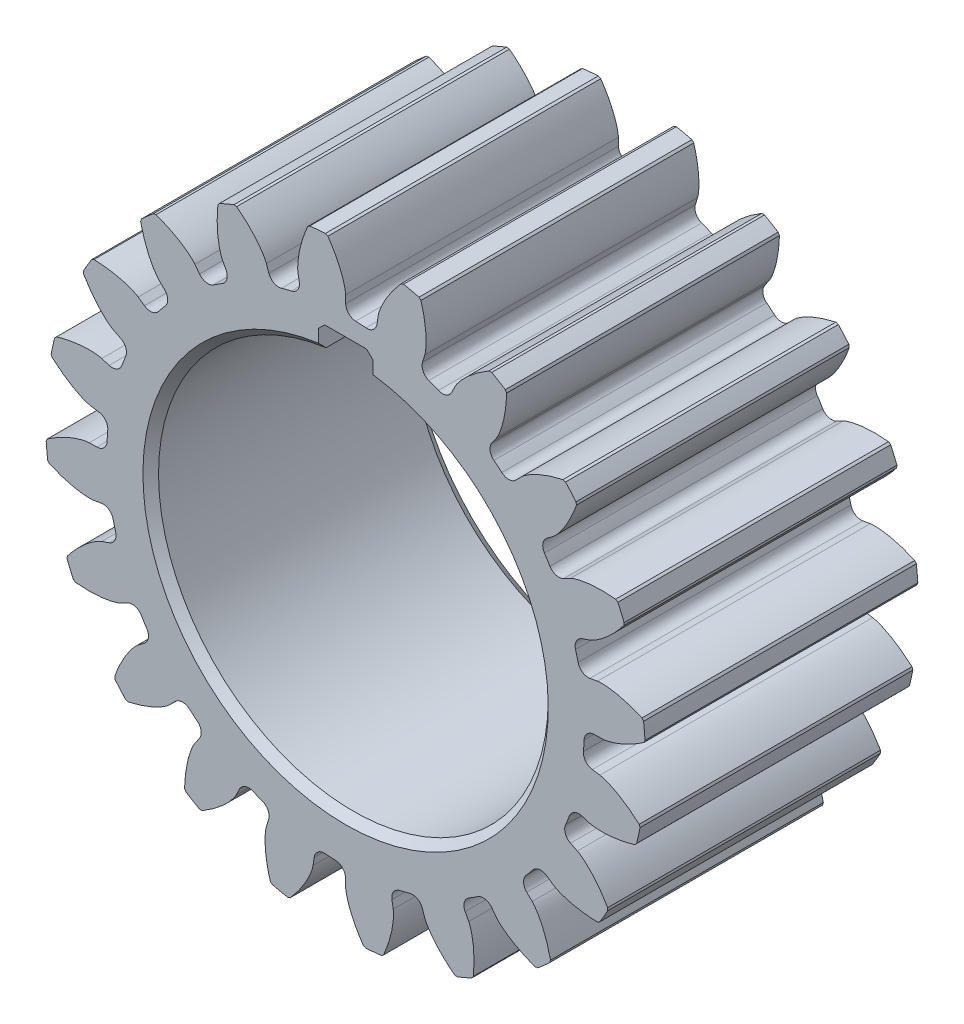
from build123d import *

# Parameters (mm, degrees)
SKETCH1_R                    = 30.625
BOSS_EXTRUDE1_DEPTH          = 35
BOSS_EXTRUDE2_DEPTH          = 35
CHAMFER1_SIZE                = 0.2
CIRPATTERN1_COUNT            = 20
CHAMFER1_OF_CIRPATTERN1_SIZE = 0.2
CUT_EXTRUDE1_DEPTH           = 35
CHAMFER2_SIZE                = 1
CHAMFER3_SIZE                = 1.6
CHAMFER4_SIZE                = 0.8


with BuildPart() as part:
    # Sketch1 → Boss-Extrude1 (new body)
    with BuildSketch(Plane.XY):
        Circle(SKETCH1_R)
    extrude(amount=BOSS_EXTRUDE1_DEPTH)

    # Sketch2 → Boss-Extrude2 (add)
    with BuildSketch(Plane.XY):
        with BuildLine():
            Line((32.8892, 0), (31.907011523, -0.014546372))
            ThreePointArc((31.907011523, -0.014546372), (30.99916734, -0.391210941), (30.597884469, -1.2884452))
            ThreePointArc((30.597884469, -1.2884452), (30.491389178, 2.857588319), (29.825681123, 6.951213604))
            ThreePointArc((29.825681123, 6.951213604), (30.386685965, 6.144162908), (31.34870745, 5.942738183))
            Line((31.34870745, 5.942738183), (32.316495712, 6.110939495))
            add(Edge.make_bspline(
                [(32.316495712, 6.110939495), (32.328235428, 6.112979855), (32.361254802, 6.118163923), (32.424031495, 6.125835398), (32.526887954, 6.135317243), (32.658500464, 6.14292963), (32.829135085, 6.14762534), (33.030708255, 6.146535461), (33.252680569, 6.138393743), (33.49451511, 6.122040937), (33.735966007, 6.099098571), (33.976890843, 6.07004769), (34.216880007, 6.035549617), (34.507456504, 5.987202414), (34.855635032, 5.920114134), (35.261931074, 5.828456236), (35.721707355, 5.70889906), (36.188774792, 5.570447222), (36.646979723, 5.420587717), (37.107925684, 5.253614676), (37.546364428, 5.08340366), (37.884256195, 4.940092177), (38.096323474, 4.847380273), (38.199445631, 4.801286645)],
                knots=[0, 0, 0, 0, 0, 0.005376749, 0.015083688, 0.02853182, 0.04661014, 0.064854849, 0.092110525, 0.119476176, 0.146842496, 0.174208854, 0.201574956, 0.228941013, 0.256307345, 0.307035032, 0.361767352, 0.416499661, 0.471231937, 0.525964282, 0.580696616, 0.635428982, 0.687157846, 0.687157846, 0.687157846, 0.687157846, 0.687157846], degree=4))
            ThreePointArc((38.199445631, 4.801286645), (38.332032109, 3.592396744), (38.426370758, 2.379922337))
            add(Edge.make_bspline(
                [(32.8892, 0), (32.901114397, 0.000176454), (32.93452202, 0.001217783), (32.997630963, 0.005344042), (33.100458131, 0.015138431), (33.231193264, 0.032112709), (33.399729081, 0.059203332), (33.597589726, 0.097727301), (33.814184042, 0.146970554), (34.048769069, 0.207972391), (34.281752769, 0.275377761), (34.513084581, 0.348687534), (34.742484906, 0.427175794), (35.019018458, 0.528671348), (35.348668844, 0.659284316), (35.730859607, 0.824837525), (36.160415556, 1.027741031), (36.593625, 1.250564909), (37.016006672, 1.482951122), (37.437901885, 1.732662166), (37.837080173, 1.981372874), (38.142460361, 2.18497044), (38.333608654, 2.315470851), (38.426370758, 2.379922337)],
                knots=[0, 0, 0, 0, 0, 0.005376749, 0.015083688, 0.02853182, 0.04661014, 0.064854849, 0.092110525, 0.119476176, 0.146842496, 0.174208854, 0.201574956, 0.228941013, 0.256307345, 0.307035032, 0.361767352, 0.416499661, 0.471231937, 0.525964282, 0.580696616, 0.635428982, 0.687157846, 0.687157846, 0.687157846, 0.687157846, 0.687157846], degree=4))
        make_face()
    boss_extrude2 = extrude(amount=BOSS_EXTRUDE2_DEPTH)

    # Chamfer1
    chamfer1_edges = [part.edges().sort_by_distance(p)[0] for p in [
        (38.199445631, 4.801286645, 17.5),
        (38.426370758, 2.379922337, 17.5),
    ]]
    chamfer(chamfer1_edges, length=CHAMFER1_SIZE)

    # CirPattern1: Boss-Extrude2 ×20 about axis
    cirpattern1_axis = Axis((0, 0, 35), (0, 0, -1))
    for i in range(1, CIRPATTERN1_COUNT):
        add(boss_extrude2.rotate(cirpattern1_axis, i * 360 / CIRPATTERN1_COUNT))

    # Chamfer1 of CirPattern1
    chamfer1_of_cirpattern1_edges = [part.edges().sort_by_distance(p)[0] for p in [
        (37.813510855, -7.237982925, 17.5),
        (37.281086755, -9.610960949, 17.5),
        (33.726126174, -18.568748297, 17.5),
        (32.486470227, -20.661056415, 17.5),
        (26.337393279, -28.081875209, 17.5),
        (24.511851647, -29.688703724, 17.5),
        (16.370572826, -34.846152518, 17.5),
        (14.137842244, -35.81021386, 17.5),
        (4.801286645, -38.199445631, 17.5),
        (2.379922337, -38.426370758, 17.5),
        (-7.237982925, -37.813510855, 17.5),
        (-9.610960949, -37.281086755, 17.5),
        (-18.568748297, -33.726126174, 17.5),
        (-20.661056415, -32.486470227, 17.5),
        (-28.081875209, -26.337393279, 17.5),
        (-29.688703724, -24.511851647, 17.5),
        (-34.846152518, -16.370572826, 17.5),
        (-35.81021386, -14.137842244, 17.5),
        (-38.199445631, -4.801286645, 17.5),
        (-38.426370758, -2.379922337, 17.5),
        (-37.813510855, 7.237982925, 17.5),
        (-37.281086755, 9.610960949, 17.5),
        (-33.726126174, 18.568748297, 17.5),
        (-32.486470227, 20.661056415, 17.5),
        (-26.337393279, 28.081875209, 17.5),
        (-24.511851647, 29.688703724, 17.5),
        (-16.370572826, 34.846152518, 17.5),
        (-14.137842244, 35.81021386, 17.5),
        (-4.801286645, 38.199445631, 17.5),
        (-2.379922337, 38.426370758, 17.5),
        (7.237982925, 37.813510855, 17.5),
        (9.610960949, 37.281086755, 17.5),
        (18.568748297, 33.726126174, 17.5),
        (20.661056415, 32.486470227, 17.5),
        (28.081875209, 26.337393279, 17.5),
        (29.688703724, 24.511851647, 17.5),
        (34.846152518, 16.370572826, 17.5),
        (35.81021386, 14.137842244, 17.5),
    ]]
    chamfer(chamfer1_of_cirpattern1_edges, length=CHAMFER1_OF_CIRPATTERN1_SIZE)

    # Sketch3 → Cut-Extrude1 (cut)
    with BuildSketch(Plane.XY):
        with BuildLine():
            Line((3.5, 24.753787589), (3.5, 28.2))
            Line((3.5, 28.2), (-3.5, 28.2))
            Line((-3.5, 28.2), (-3.5, 24.753787589))
            ThreePointArc((-3.5, 24.753787589), (0, -25), (3.5, 24.753787589))
        make_face()
    extrude(amount=CUT_EXTRUDE1_DEPTH, mode=Mode.SUBTRACT)

    # Chamfer2
    chamfer2_edges = [part.edges().sort_by_distance(p)[0] for p in [
        (0, -25, 35),
    ]]
    chamfer(chamfer2_edges, length=CHAMFER2_SIZE)

    # Chamfer3
    chamfer3_edges = [part.edges().sort_by_distance(p)[0] for p in [
        (0, -25, 0),
    ]]
    chamfer(chamfer3_edges, length=CHAMFER3_SIZE)

    # Chamfer4
    chamfer4_edges = [part.edges().sort_by_distance(p)[0] for p in [
        (3.5, 28.2, 17.5),
        (-3.5, 28.2, 17.5),
    ]]
    chamfer(chamfer4_edges, length=CHAMFER4_SIZE)


solid = part.part
